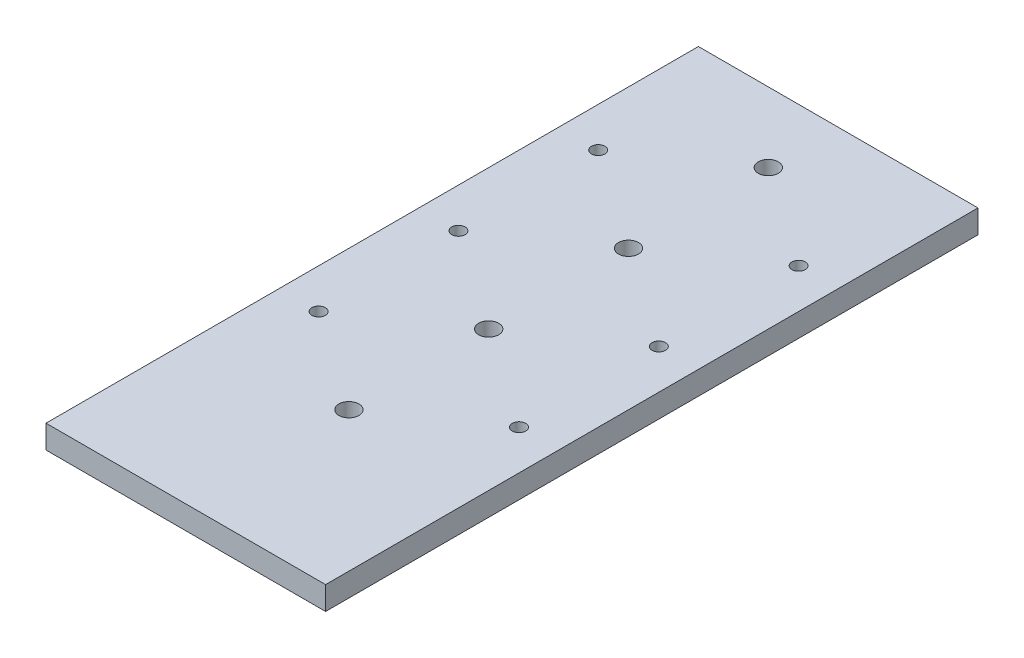
from build123d import *

# Parameters (mm, degrees)
SKETCH1_W           = 76.2
SKETCH1_H           = 177.8
SKETCH1_R           = 2.7305
SKETCH1_R_2         = 1.8288
BOSS_EXTRUDE1_DEPTH = 6.35


with BuildPart() as part:
    # Sketch1 → Boss-Extrude1 (new body)
    with BuildSketch(Plane(origin=(0, 0, 0), x_dir=(1, 0, 0), z_dir=(0, 1, 0))):
        Rectangle(SKETCH1_W, SKETCH1_H)
        with Locations((0, 69.85)):
            Circle(SKETCH1_R, mode=Mode.SUBTRACT)
        with Locations((0, 31.75)):
            Circle(SKETCH1_R, mode=Mode.SUBTRACT)
        with Locations((0, -6.35)):
            Circle(SKETCH1_R, mode=Mode.SUBTRACT)
        with Locations((0, -44.45)):
            Circle(SKETCH1_R, mode=Mode.SUBTRACT)
        with Locations((27.305, 50.8)):
            Circle(SKETCH1_R_2, mode=Mode.SUBTRACT)
        with Locations((27.305, 12.7)):
            Circle(SKETCH1_R_2, mode=Mode.SUBTRACT)
        with Locations((27.305, -25.4)):
            Circle(SKETCH1_R_2, mode=Mode.SUBTRACT)
        with Locations((-27.305, 12.7)):
            Circle(SKETCH1_R_2, mode=Mode.SUBTRACT)
        with Locations((-27.305, -25.4)):
            Circle(SKETCH1_R_2, mode=Mode.SUBTRACT)
        with Locations((-27.305, 50.8)):
            Circle(SKETCH1_R_2, mode=Mode.SUBTRACT)
    extrude(amount=-BOSS_EXTRUDE1_DEPTH)


solid = part.part
